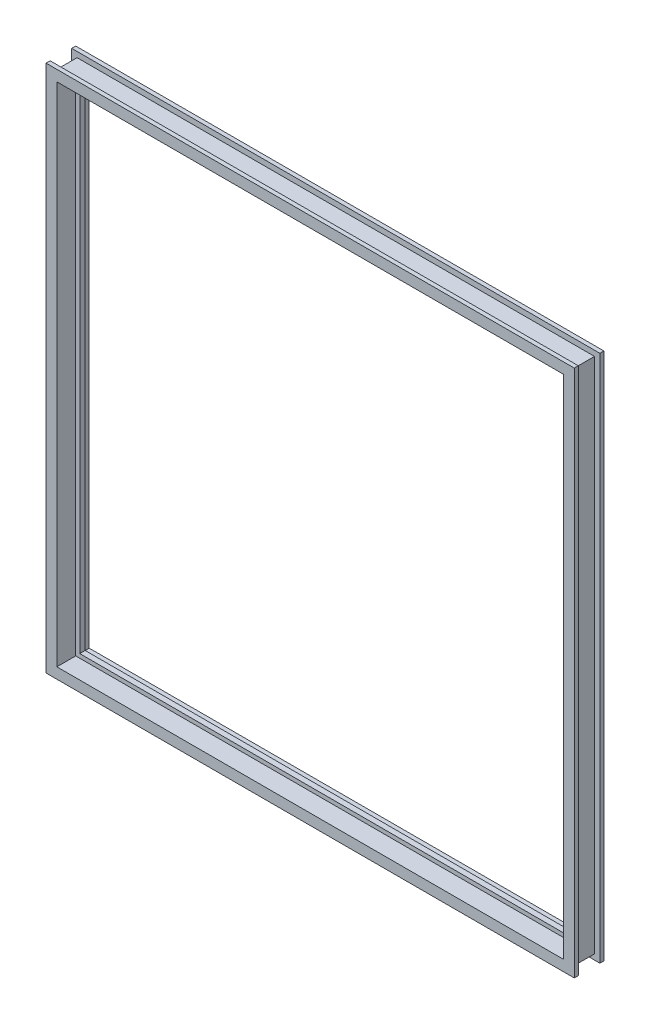
from build123d import *


with BuildPart() as part:
    # Sweep1: sweep along a path in Sketch2
    with BuildLine(Plane.XY) as sweep1_path:
        Line((304.8, 609.6), (-304.8, 609.6))
        Line((-304.8, 609.6), (-304.8, 0))
        Line((-304.8, 0), (304.8, 0))
        Line((304.8, 0), (304.8, 609.6))
    # Sketch1 → Sweep1 (sweep)
    with BuildSketch(Plane(origin=(0, 0, 0), x_dir=(0, 0, -1), z_dir=(1, 0, 0))):
        Polygon((-12.7, -6.35), (-17.4625, -6.35), (-17.4625, 6.35), (4.7625, 6.35), (4.7625, 11.1125), (11.1125, 11.1125), (11.1125, 9.525), (17.4625, 9.525), (17.4625, -6.35), (12.7, -6.35), (12.7, 0), (-12.7, 0), align=None)
    sweep(path=sweep1_path.line, transition=Transition.RIGHT)


solid = part.part
